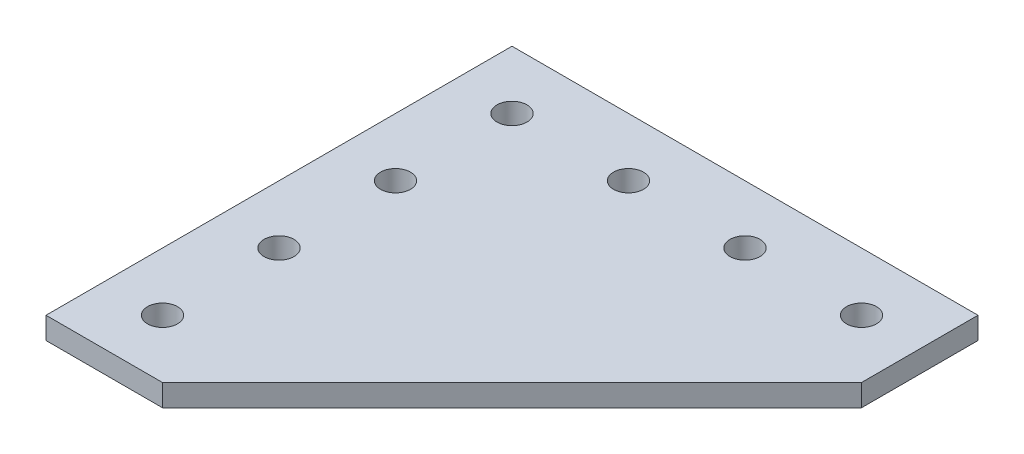
from build123d import *

# Parameters (mm, degrees)
SKETCH1_R           = 3.2639
BOSS_EXTRUDE1_DEPTH = 4.7752


with BuildPart() as part:
    # Sketch1 (on Top Plane) → Boss-Extrude1 (new body)
    with BuildSketch(Plane(origin=(0, 0, 0), x_dir=(1, 0, 0), z_dir=(0, 1, 0))):
        Polygon((0, 0), (-101.6, 0), (-101.6, -101.6), (-76.2, -101.6), (0, -25.4), align=None)
        with Locations(Location((-88.9, -88.9, 0), (0, 0, 90))):
            Circle(SKETCH1_R, mode=Mode.SUBTRACT)
        with Locations(Location((-88.9, -63.5, 0), (0, 0, 90))):
            Circle(SKETCH1_R, mode=Mode.SUBTRACT)
        with Locations(Location((-38.1, -12.7, 0), (0, 0, 90))):
            Circle(SKETCH1_R, mode=Mode.SUBTRACT)
        with Locations(Location((-63.5, -12.7, 0), (0, 0, 90))):
            Circle(SKETCH1_R, mode=Mode.SUBTRACT)
        with Locations(Location((-88.9, -12.7, 0), (0, 0, 90))):
            Circle(SKETCH1_R, mode=Mode.SUBTRACT)
        with Locations(Location((-88.9, -38.1, 0), (0, 0, 90))):
            Circle(SKETCH1_R, mode=Mode.SUBTRACT)
        with Locations(Location((-12.7, -12.7, 0), (0, 0, 90))):
            Circle(SKETCH1_R, mode=Mode.SUBTRACT)
    extrude(amount=-BOSS_EXTRUDE1_DEPTH)


solid = part.part
